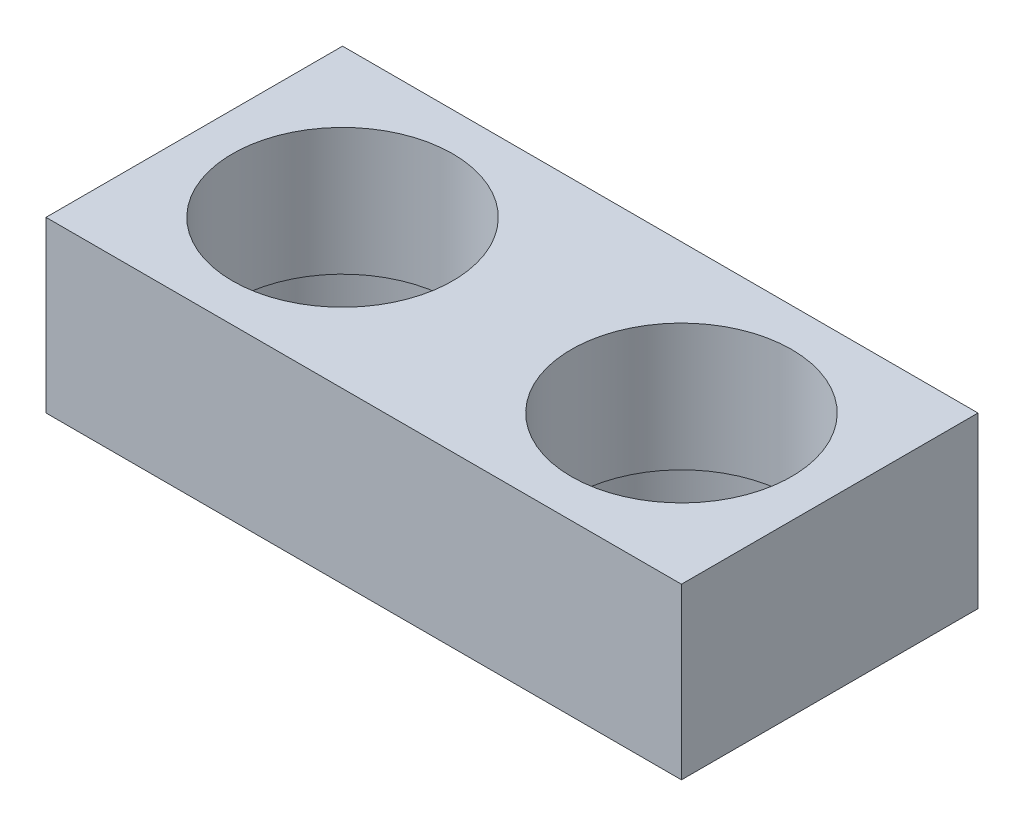
from build123d import *

# Parameters (mm, degrees)
CROQUIS1_W              = 15
CROQUIS1_H              = 7
CROQUIS1_R              = 2.6
SALIENTE_EXTRUIR1_DEPTH = 4
CROQUIS2_R              = 3
CORTAR_EXTRUIR1_DEPTH   = 1


with BuildPart() as part:
    # Croquis1 → Saliente-Extruir1 (new body)
    with BuildSketch(Plane(origin=(0, 0, 0), x_dir=(1, 0, 0), z_dir=(0, 1, 0))):
        with Locations((-4, 0)):
            Rectangle(CROQUIS1_W, CROQUIS1_H)
        Circle(CROQUIS1_R, mode=Mode.SUBTRACT)
        with Locations((-8, 0)):
            Circle(CROQUIS1_R, mode=Mode.SUBTRACT)
    extrude(amount=SALIENTE_EXTRUIR1_DEPTH)

    # Croquis2 → Cortar-Extruir1 (cut)
    with BuildSketch(Plane.XZ):
        Circle(CROQUIS2_R)
        with Locations((-8, 0)):
            Circle(CROQUIS2_R)
    extrude(amount=-CORTAR_EXTRUIR1_DEPTH, mode=Mode.SUBTRACT)


solid = part.part
